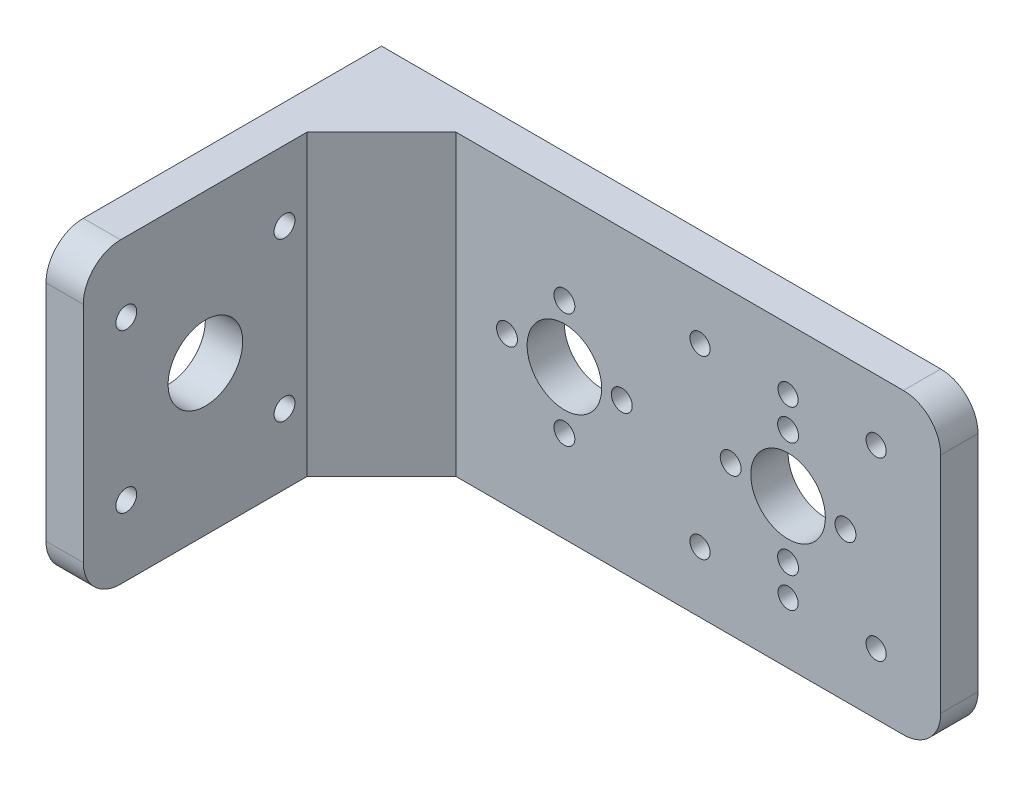
from build123d import *

# Parameters (mm, degrees)
SKETCH1_W                 = 101.6
SKETCH1_H                 = 50.8
BOSS_EXTRUDE1_DEPTH       = 6.35
SKETCH2_R                 = 1.7145
CUT_EXTRUDE1_DEPTH        = 6.35
SKETCH3_R                 = 1.778
CUT_EXTRUDE2_DEPTH        = 6.35
SKETCH4_R                 = 6.35
CUT_EXTRUDE3_DEPTH        = 6.35
CIRPATTERN1_COUNT         = 4
SKETCH5_W                 = 6.35
SKETCH5_H                 = 50.8
BOSS_EXTRUDE2_DEPTH       = 50.8
SKETCH6_R                 = 6.35
CUT_EXTRUDE4_DEPTH        = 6.35
SKETCH7_R                 = 1.778
CUT_EXTRUDE5_DEPTH        = 6.35
CIRPATTERN2_COUNT         = 4
LPATTERN1_COUNT           = 2
LPATTERN1_PITCH           = 38.1
LPATTERN1_COPY_1_SKETCH_R = 1.778
LPATTERN1_COPY_1_DEPTH    = 6.35
LPATTERN1_COPY_2_SKETCH_R = 1.778
LPATTERN1_COPY_2_DEPTH    = 6.35
LPATTERN1_COPY_3_SKETCH_R = 1.778
LPATTERN1_COPY_3_DEPTH    = 6.35
BOSS_EXTRUDE3_DEPTH       = 50.8
FILLET1_R                 = 6.35


with BuildPart() as part:
    # Sketch1 → Boss-Extrude1 (new body)
    with BuildSketch(Plane.XY):
        with Locations((-50.8, -25.4)):
            Rectangle(SKETCH1_W, SKETCH1_H)
    extrude(amount=BOSS_EXTRUDE1_DEPTH)

    # Sketch2 → Cut-Extrude1 (cut)
    with BuildSketch(Plane.XY.offset(6.35)):
        with Locations((-11, -10.400000028)):
            Circle(SKETCH2_R)
        with Locations((-41, -10.400000028)):
            Circle(SKETCH2_R)
        with Locations((-41, -40.399999972)):
            Circle(SKETCH2_R)
        with Locations((-11, -40.399999972)):
            Circle(SKETCH2_R)
        with Locations((-25.999999972, -40.399999972)):
            Circle(SKETCH2_R)
        with Locations((-25.999999972, -10.400000028)):
            Circle(SKETCH2_R)
    extrude(amount=-CUT_EXTRUDE1_DEPTH, mode=Mode.SUBTRACT)

    # Sketch3 → Cut-Extrude2 (cut)
    with BuildSketch(Plane.XY.offset(6.35)):
        with Locations((-26, -15.621)):
            Circle(SKETCH3_R)
    cut_extrude2 = extrude(amount=-CUT_EXTRUDE2_DEPTH, mode=Mode.SUBTRACT)

    # Sketch4 → Cut-Extrude3 (cut)
    with BuildSketch(Plane.XY.offset(6.35)):
        with Locations((-26, -25.4)):
            Circle(SKETCH4_R)
    cut_extrude3 = extrude(amount=-CUT_EXTRUDE3_DEPTH, mode=Mode.SUBTRACT)

    # CirPattern1: Cut-Extrude2 ×4 about axis
    cirpattern1_axis = Axis((-26, -25.4, 0), (0, 0, 1))
    for i in range(1, CIRPATTERN1_COUNT):
        add(cut_extrude2.rotate(cirpattern1_axis, i * 360 / CIRPATTERN1_COUNT), mode=Mode.SUBTRACT)

    # Sketch5 → Boss-Extrude2 (add)
    with BuildSketch(Plane.XY.offset(6.35)):
        with Locations((-98.425, -25.4)):
            Rectangle(SKETCH5_W, SKETCH5_H)
    extrude(amount=BOSS_EXTRUDE2_DEPTH)

    # Sketch6 → Cut-Extrude4 (cut)
    with BuildSketch(Plane(origin=(-95.25, 0, 0), x_dir=(0, 0, -1), z_dir=(1, 0, 0))):
        with Locations((-36.35, -25.4)):
            Circle(SKETCH6_R)
    extrude(amount=-CUT_EXTRUDE4_DEPTH, mode=Mode.SUBTRACT)

    # Sketch7 → Cut-Extrude5 (cut)
    with BuildSketch(Plane(origin=(-95.25, 0, 0), x_dir=(0, 0, -1), z_dir=(1, 0, 0))):
        with Locations((-49.8247, -11.9253)):
            Circle(SKETCH7_R)
    cut_extrude5 = extrude(amount=-CUT_EXTRUDE5_DEPTH, mode=Mode.SUBTRACT)

    # CirPattern2: Cut-Extrude5 ×4 about axis
    cirpattern2_axis = Axis((0, -25.4, 36.35), (1, 0, 0))
    for i in range(1, CIRPATTERN2_COUNT):
        add(cut_extrude5.rotate(cirpattern2_axis, i * 360 / CIRPATTERN2_COUNT), mode=Mode.SUBTRACT)

    # LPattern1: Cut-Extrude3, Cut-Extrude2 ×2
    with Locations(*[(-i * LPATTERN1_PITCH, 0, 0) for i in range(1, LPATTERN1_COUNT)]):
        add(cut_extrude3, mode=Mode.SUBTRACT)
        add(cut_extrude2, mode=Mode.SUBTRACT)

    # LPattern1 copy 1 sketch → LPattern1 copy 1 (cut)
    with BuildSketch(Plane(origin=(-89.5, 0.6, 6.35), x_dir=(0, 1, 0), z_dir=(0, 0, 1))):
        with Locations((-26, -15.621)):
            Circle(LPATTERN1_COPY_1_SKETCH_R)
    extrude(amount=-LPATTERN1_COPY_1_DEPTH, mode=Mode.SUBTRACT)

    # LPattern1 copy 2 sketch → LPattern1 copy 2 (cut)
    with BuildSketch(Plane(origin=(-90.1, -50.8, 6.35), x_dir=(-1, 0, 0), z_dir=(0, 0, 1))):
        with Locations((-26, -15.621)):
            Circle(LPATTERN1_COPY_2_SKETCH_R)
    extrude(amount=-LPATTERN1_COPY_2_DEPTH, mode=Mode.SUBTRACT)

    # LPattern1 copy 3 sketch → LPattern1 copy 3 (cut)
    with BuildSketch(Plane(origin=(-38.7, -51.4, 6.35), x_dir=(0, -1, 0), z_dir=(0, 0, 1))):
        with Locations((-26, -15.621)):
            Circle(LPATTERN1_COPY_3_SKETCH_R)
    extrude(amount=-LPATTERN1_COPY_3_DEPTH, mode=Mode.SUBTRACT)

    # Sketch8 → Boss-Extrude3 (add)
    with BuildSketch(Plane.XZ.offset(50.8)):
        Polygon((-95.25, 6.35), (-95.25, 19.05), (-82.55, 6.35), align=None)
    extrude(amount=-BOSS_EXTRUDE3_DEPTH)

    # Fillet1
    fillet1_edges = [part.edges().sort_by_distance(p)[0] for p in [
        (-98.425, -50.8, 57.15),
        (-98.425, 0, 57.15),
        (0, -50.8, 3.175),
        (0, 0, 3.175),
    ]]
    fillet(fillet1_edges, radius=FILLET1_R)


solid = part.part
